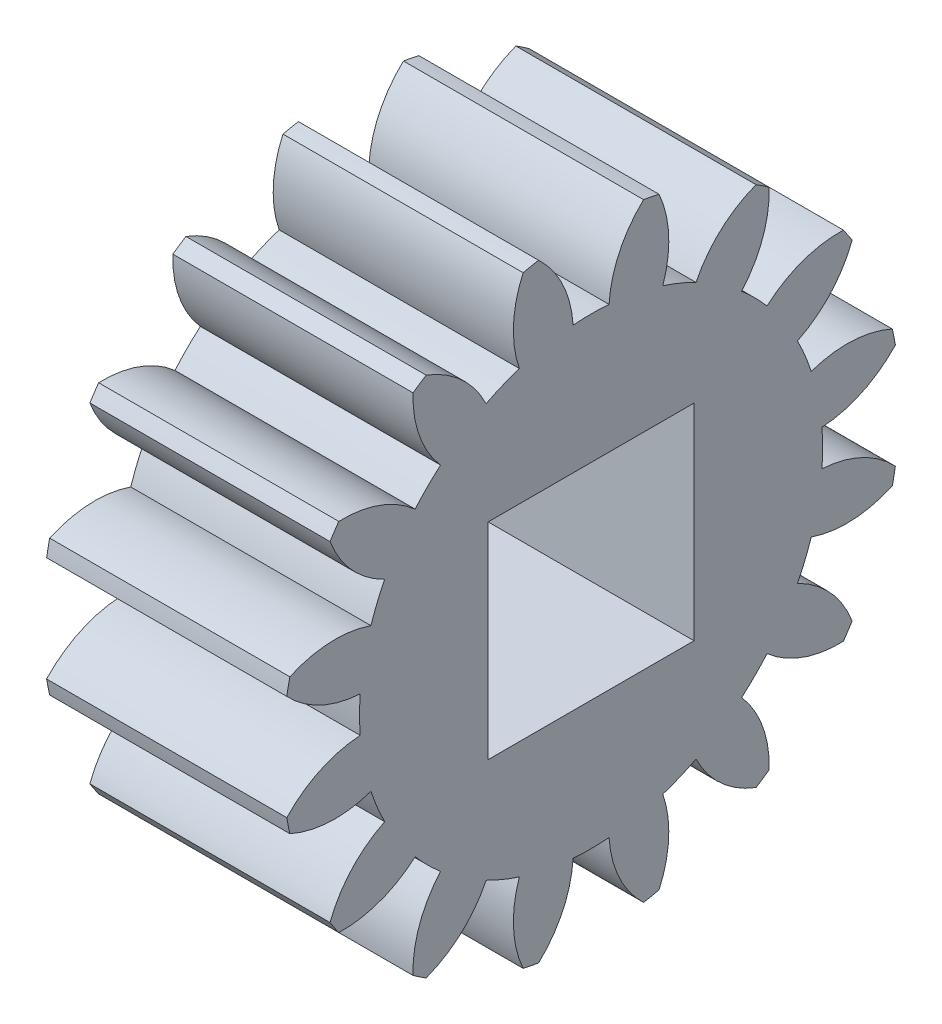
from build123d import *

# Parameters (mm, degrees)
BASPROSKE_W        = 7
BASPROSKE_H        = 9
TOOTHCUT_DEPTH     = 15.525839046
TEETHCUTS_COUNT    = 16
BORSKE_R           = 3
BORE_DEPTH         = 50.0001016
SKETCH1_W          = 6
SKETCH1_H          = 6
CUT_EXTRUDE1_DEPTH = 10


with BuildPart() as part:
    # BasProSke → Base-Revolve (revolve)
    with BuildSketch(Plane(origin=(0, 0, 0), x_dir=(1, 0, 0), z_dir=(0, 1, 0)), mode=Mode.PRIVATE) as base_revolve_sk:
        with Locations((3.5, 4.5)):
            Rectangle(BASPROSKE_W, BASPROSKE_H)
    revolve(base_revolve_sk.sketch.rotate(Axis((-10, 0, 0), (1, 0, 0)), 180), axis=Axis((-10, 0, 0), (1, 0, 0)))

    # TooCutSke → ToothCut (cut, through all)
    with BuildSketch(Plane(origin=(0, 0, 0), x_dir=(0, 0, -1), z_dir=(1, 0, 0))):
        with BuildLine():
            ThreePointArc((0.523792937, 6.728643397), (0, 6.749), (-0.523792937, 6.728643397))
            ThreePointArc((-0.523792937, 6.728643397), (-0.828704482, 7.90962059), (-1.553355277, 8.890721711))
            ThreePointArc((-1.553355277, 8.890721711), (0, 9.0254), (1.553355277, 8.890721711))
            ThreePointArc((1.553355277, 8.890721711), (0.828704482, 7.90962059), (0.523792937, 6.728643397))
        make_face()
    toothcut = extrude(amount=TOOTHCUT_DEPTH, mode=Mode.SUBTRACT)

    # TeethCuts: ToothCut ×16 about axis
    teethcuts_axis = Axis((0, 0, 0), (1, 0, 0))
    for i in range(1, TEETHCUTS_COUNT):
        add(toothcut.rotate(teethcuts_axis, i * 360 / TEETHCUTS_COUNT), mode=Mode.SUBTRACT)

    # BorSke → Bore (cut, symmetric)
    with BuildSketch(Plane(origin=(0, 0, 0), x_dir=(0, 0, -1), z_dir=(1, 0, 0))):
        with Locations(Location((0, 0, 0), (0, 0, 180))):
            Circle(BORSKE_R)
    extrude(amount=BORE_DEPTH, both=True, mode=Mode.SUBTRACT)

    # Sketch1 → Cut-Extrude1 (cut)
    with BuildSketch(Plane(origin=(7, 0, 0), x_dir=(0, 0, -1), z_dir=(1, 0, 0))):
        Rectangle(SKETCH1_W, SKETCH1_H)
    extrude(amount=-CUT_EXTRUDE1_DEPTH, mode=Mode.SUBTRACT)


solid = part.part
